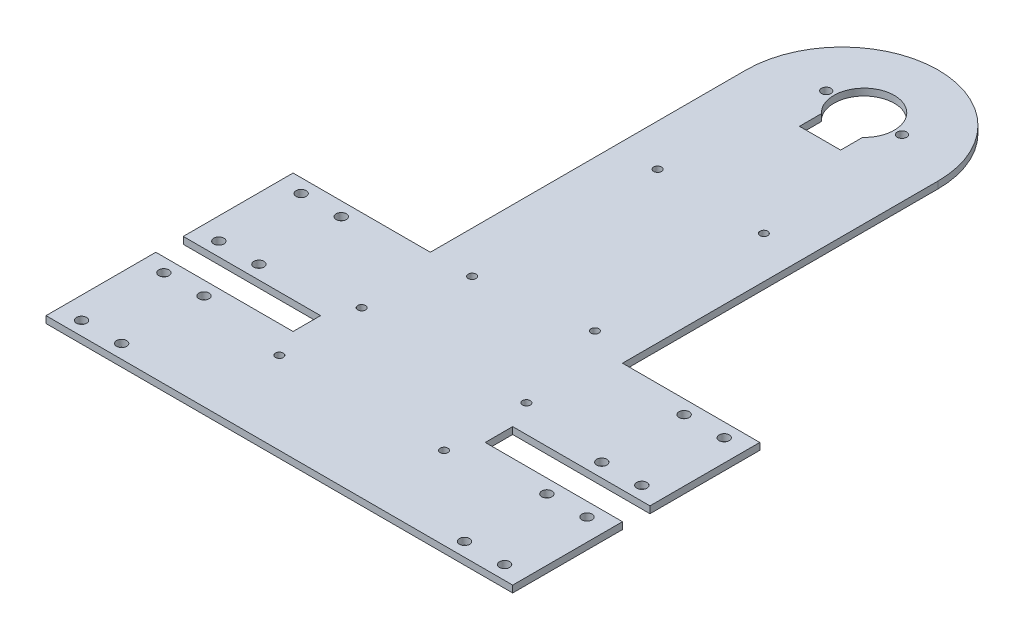
from build123d import *

# Parameters (mm, degrees)
BOSS_EXTRUDE1_DEPTH = 3.175
SKETCH2_R           = 1.80975
SKETCH2_R_2         = 2.159
CUT_EXTRUDE1_DEPTH  = 187.786089217
SKETCH3_R           = 2.3495
CUT_EXTRUDE2_DEPTH  = 187.786089217


with BuildPart() as part:
    # Sketch1 → Boss-Extrude1 (new body)
    with BuildSketch(Plane(origin=(0, 0, 0), x_dir=(1, 0, 0), z_dir=(0, 1, 0))):
        with BuildLine():
            ThreePointArc((44.45, 107.95), (0, 152.4), (-44.45, 107.95))
            Line((-44.45, 107.95), (-44.45, -38.1))
            Line((-44.45, -38.1), (-107.95, -38.1))
            Line((-107.95, -38.1), (-107.95, -88.9))
            Line((-107.95, -88.9), (-44.45, -88.9))
            Line((-44.45, -88.9), (-44.45, -101.6))
            Line((-44.45, -101.6), (-107.95, -101.6))
            Line((-107.95, -101.6), (-107.95, -152.4))
            Line((-107.95, -152.4), (107.95, -152.4))
            Line((107.95, -152.4), (107.95, -101.6))
            Line((107.95, -101.6), (44.45, -101.6))
            Line((44.45, -101.6), (44.45, -88.9))
            Line((44.45, -88.9), (107.95, -88.9))
            Line((107.95, -88.9), (107.95, -38.1))
            Line((107.95, -38.1), (44.45, -38.1))
            Line((44.45, -38.1), (44.45, 107.95))
        make_face()
    extrude(amount=BOSS_EXTRUDE1_DEPTH)

    # Sketch2 → Cut-Extrude1 (cut, through all)
    with BuildSketch(Plane(origin=(0, 3.175, 0), x_dir=(1, 0, 0), z_dir=(0, 1, 0))):
        with BuildLine():
            ThreePointArc((9.525, 107.890642143), (0, 132.08), (-9.525, 107.890642143))
            Line((-9.525, 107.890642143), (-9.525, 97.730642143))
            Line((-9.525, 97.730642143), (9.525, 97.730642143))
            Line((9.525, 97.730642143), (9.525, 107.890642143))
        make_face()
        with Locations((-38.1, -76.2)):
            Circle(SKETCH2_R)
        with Locations((38.1, -76.2)):
            Circle(SKETCH2_R)
        with Locations((-38.1, -114.3)):
            Circle(SKETCH2_R)
        with Locations((38.1, -114.3)):
            Circle(SKETCH2_R)
        with Locations((-25.14473, 47.72914)):
            Circle(SKETCH2_R)
        with Locations((25.14473, 46.58614)):
            Circle(SKETCH2_R)
        with Locations((25.14473, -31.56966)):
            Circle(SKETCH2_R)
        with Locations((-25.14473, -38.1)):
            Circle(SKETCH2_R)
        with Locations((-17.526, 118.11)):
            Circle(SKETCH2_R_2)
        with Locations((17.526, 118.11)):
            Circle(SKETCH2_R_2)
    extrude(amount=-CUT_EXTRUDE1_DEPTH, mode=Mode.SUBTRACT)

    # Sketch3 → Cut-Extrude2 (cut, through all)
    with BuildSketch(Plane(origin=(0, 3.175, 0), x_dir=(1, 0, 0), z_dir=(0, 1, 0))):
        with Locations((-97.8535, -44.45)):
            Circle(SKETCH3_R)
        with Locations((-79.3115, -44.45)):
            Circle(SKETCH3_R)
        with Locations((-97.8535, -82.55)):
            Circle(SKETCH3_R)
        with Locations((-79.3115, -82.55)):
            Circle(SKETCH3_R)
        with Locations((-79.3115, -107.95)):
            Circle(SKETCH3_R)
        with Locations((-97.8535, -107.95)):
            Circle(SKETCH3_R)
        with Locations((-79.3115, -146.05)):
            Circle(SKETCH3_R)
        with Locations((-97.8535, -146.05)):
            Circle(SKETCH3_R)
        with Locations((97.8535, -146.05)):
            Circle(SKETCH3_R)
        with Locations((79.3115, -146.05)):
            Circle(SKETCH3_R)
        with Locations((97.8535, -107.95)):
            Circle(SKETCH3_R)
        with Locations((79.3115, -107.95)):
            Circle(SKETCH3_R)
        with Locations((79.3115, -82.55)):
            Circle(SKETCH3_R)
        with Locations((97.8535, -82.55)):
            Circle(SKETCH3_R)
        with Locations((79.3115, -44.45)):
            Circle(SKETCH3_R)
        with Locations((97.8535, -44.45)):
            Circle(SKETCH3_R)
    extrude(amount=-CUT_EXTRUDE2_DEPTH, mode=Mode.SUBTRACT)


solid = part.part
